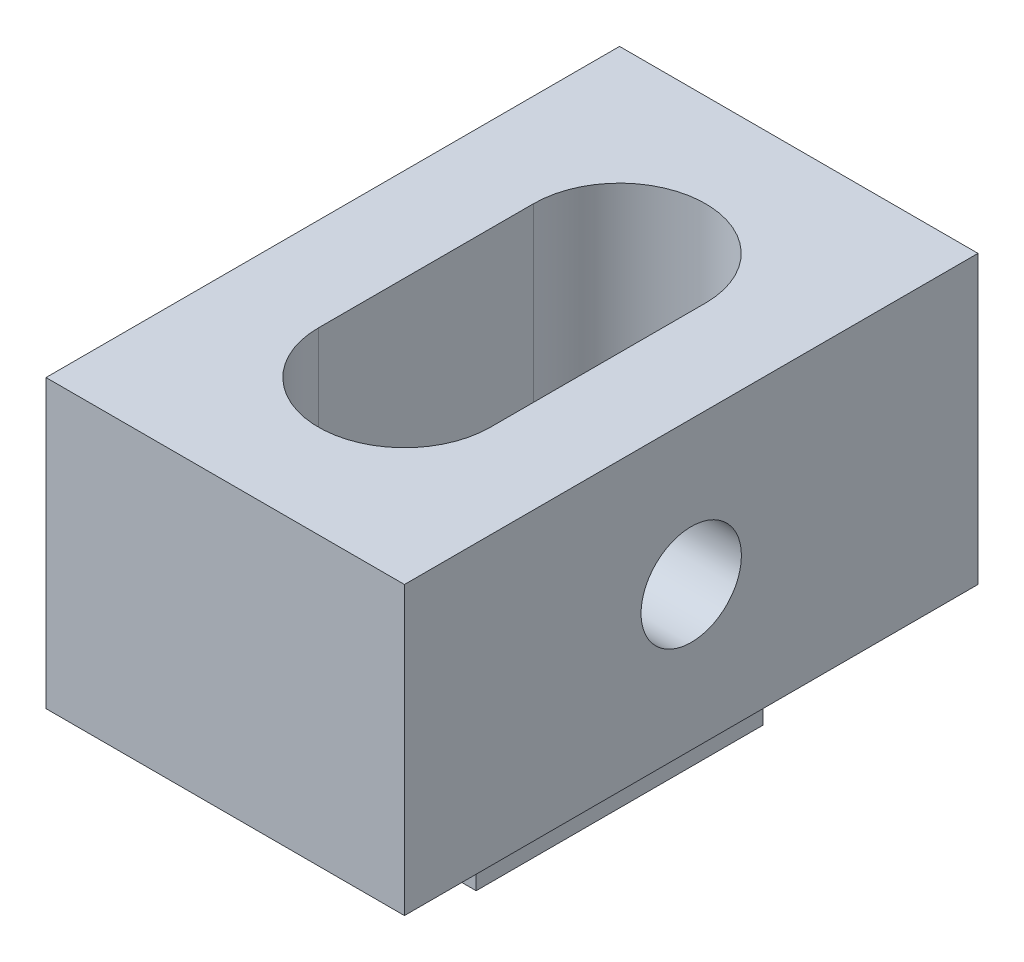
from build123d import *

# Parameters (mm, degrees)
SKETCH1_W           = 25
SKETCH1_H           = 20
BOSS_EXTRUDE1_DEPTH = 20
CUT_EXTRUDE1_DEPTH  = 18
HOLE1_D             = 7
HOLE1_DEPTH         = 6.5
SKETCH6_W           = 15
SKETCH6_H           = 20
BOSS_EXTRUDE2_DEPTH = 6


with BuildPart() as part:
    # Sketch1 → Boss-Extrude1 (new body, symmetric)
    with BuildSketch(Plane.XY):
        with Locations((12.5, 10)):
            Rectangle(SKETCH1_W, SKETCH1_H)
    extrude(amount=BOSS_EXTRUDE1_DEPTH, both=True)

    # Sketch2 → Cut-Extrude1 (cut)
    with BuildSketch(Plane(origin=(0, 20, 0), x_dir=(1, 0, 0), z_dir=(0, 1, 0))):
        with BuildLine():
            Line((6.5, 7.5), (6.5, -7.5))
            ThreePointArc((6.5, -7.5), (12.5, -13.5), (18.5, -7.5))
            Line((18.5, -7.5), (18.5, 7.5))
            ThreePointArc((18.5, 7.5), (12.5, 13.5), (6.5, 7.5))
        make_face()
    extrude(amount=-CUT_EXTRUDE1_DEPTH, mode=Mode.SUBTRACT)

    # Hole1
    with Locations(Plane(origin=(25, 0, 0), x_dir=(0, 0, -1), z_dir=(1, 0, 0))):
        with Locations((0, 10)):
            Hole(HOLE1_D / 2, depth=HOLE1_DEPTH)

    # Sketch6 → Boss-Extrude2 (add)
    with BuildSketch(Plane(origin=(0, 0, 0), x_dir=(1, 0, 0), z_dir=(0, 1, 0))):
        with Locations((12.5, 0)):
            Rectangle(SKETCH6_W, SKETCH6_H)
    extrude(amount=-BOSS_EXTRUDE2_DEPTH)


solid = part.part
